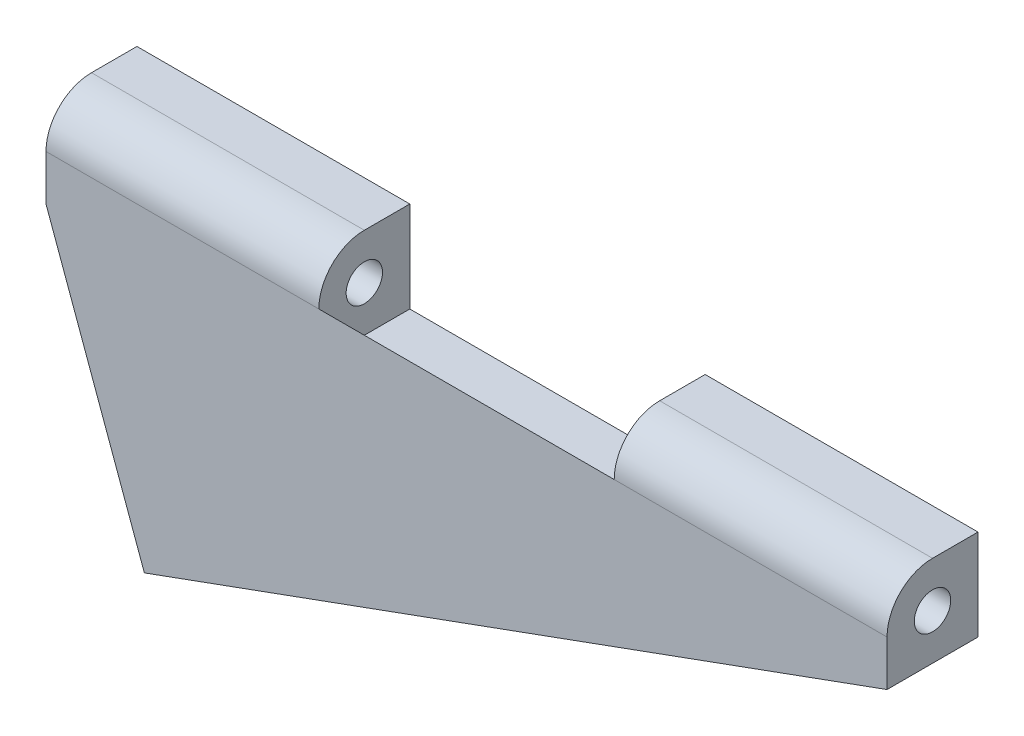
from build123d import *

# Parameters (mm, degrees)
BOSS_EXTRUDE1_DEPTH = 6.35
SKETCH3_R           = 3.175
SKETCH3_R_2         = 1.27
BOSS_EXTRUDE3_DEPTH = 58.720417
CUT_EXTRUDE3_START  = -19.05
SKETCH3_7_R         = 3.175
SKETCH3_7_R_2       = 1.27
CUT_EXTRUDE3_DEPTH  = 20.620416805


with BuildPart() as part:
    # Sketch1 → Boss-Extrude1 (new body)
    with BuildSketch(Plane.XY):
        Polygon((-51.851432898, -18.872378179), (0, 0), (-58.720416805, 0), align=None)
    extrude(amount=BOSS_EXTRUDE1_DEPTH)

    # Sketch3 → Boss-Extrude3 (add)
    with BuildSketch(Plane(origin=(0, 0, 0), x_dir=(0, 0, -1), z_dir=(1, 0, 0))):
        with Locations((-3.175, 3.175)):
            Circle(SKETCH3_R)
        with Locations((-3.175, 3.175)):
            Circle(SKETCH3_R_2, mode=Mode.SUBTRACT)
        with BuildLine():
            Line((0, 0), (0, 3.175))
            ThreePointArc((0, 3.175), (-0.92993597, 0.92993597), (-3.175, 0))
            Line((-3.175, 0), (0, 0))
        make_face()
        with BuildLine():
            Line((0, 6.35), (-3.175, 6.35))
            ThreePointArc((-3.175, 6.35), (-0.92993597, 5.42006403), (0, 3.175))
            Line((0, 3.175), (0, 6.35))
        make_face()
        with BuildLine():
            ThreePointArc((-3.175, 0), (-5.42006403, 0.92993597), (-6.35, 3.175))
            Line((-6.35, 3.175), (-6.35, 0))
            Line((-6.35, 0), (-3.175, 0))
        make_face()
    extrude(amount=-BOSS_EXTRUDE3_DEPTH)

    # Sketch3_7 → Cut-Extrude3 (cut)
    with BuildSketch(Plane(origin=(0, 0, 0), x_dir=(0, 0, -1), z_dir=(1, 0, 0)).offset(CUT_EXTRUDE3_START)):
        with Locations((-3.175, 3.175)):
            Circle(SKETCH3_7_R)
        with Locations((-3.175, 3.175)):
            Circle(SKETCH3_7_R_2, mode=Mode.SUBTRACT)
        with BuildLine():
            Line((0, 6.35), (-3.175, 6.35))
            ThreePointArc((-3.175, 6.35), (-0.92993597, 5.42006403), (0, 3.175))
            Line((0, 3.175), (0, 6.35))
        make_face()
        with BuildLine():
            Line((0, 0), (0, 3.175))
            ThreePointArc((0, 3.175), (-0.92993597, 0.92993597), (-3.175, 0))
            Line((-3.175, 0), (0, 0))
        make_face()
    extrude(amount=-CUT_EXTRUDE3_DEPTH, mode=Mode.SUBTRACT)


solid = part.part
